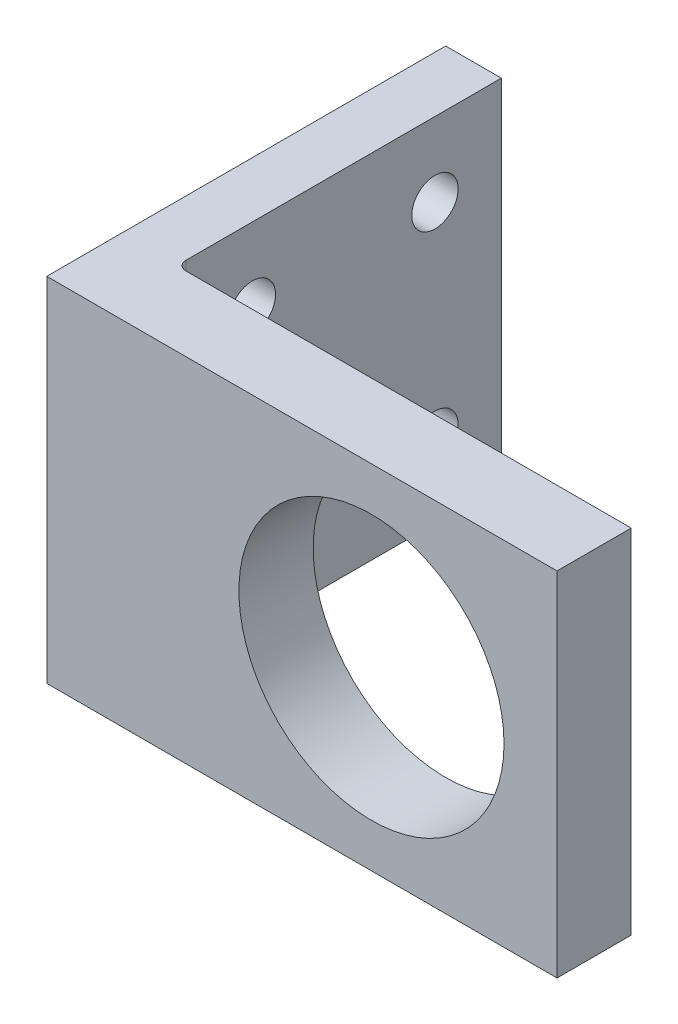
from build123d import *

# Parameters (mm, degrees)
SKETCH1_W           = 55
SKETCH1_H           = 38
SKETCH1_R           = 14.2875
BOSS_EXTRUDE3_DEPTH = 8
SKETCH8_W           = 6
SKETCH8_H           = 38
BOSS_EXTRUDE6_DEPTH = 35
FILLET1_R           = 1
SKETCH9_R           = 2.5
CUT_EXTRUDE1_DEPTH  = 10


with BuildPart() as part:
    # Sketch1 → Boss-Extrude3 (new body)
    with BuildSketch(Plane.XY):
        with Locations((27.5, 19)):
            Rectangle(SKETCH1_W, SKETCH1_H)
        with Locations((35, 19)):
            Circle(SKETCH1_R, mode=Mode.SUBTRACT)
    extrude(amount=BOSS_EXTRUDE3_DEPTH)

    # Sketch8 → Boss-Extrude6 (add)
    with BuildSketch(Plane(origin=(0, 0, 0), x_dir=(-1, 0, 0), z_dir=(0, 0, -1))):
        with Locations((-3, 19)):
            Rectangle(SKETCH8_W, SKETCH8_H)
    extrude(amount=BOSS_EXTRUDE6_DEPTH)

    # Fillet1
    fillet1_edges = [part.edges().sort_by_distance(p)[0] for p in [
        (6, 19, 0),
    ]]
    fillet(fillet1_edges, radius=FILLET1_R)

    # Sketch9 → Cut-Extrude1 (cut)
    with BuildSketch(Plane(origin=(6, 0, 0), x_dir=(0, 0, -1), z_dir=(1, 0, 0))):
        with Locations((8.157894737, 30)):
            Circle(SKETCH9_R)
        with Locations((8.157894737, 8)):
            Circle(SKETCH9_R)
        with Locations((27.842105263, 8)):
            Circle(SKETCH9_R)
        with Locations((27.842105263, 30)):
            Circle(SKETCH9_R)
    extrude(amount=-CUT_EXTRUDE1_DEPTH, mode=Mode.SUBTRACT)


solid = part.part
